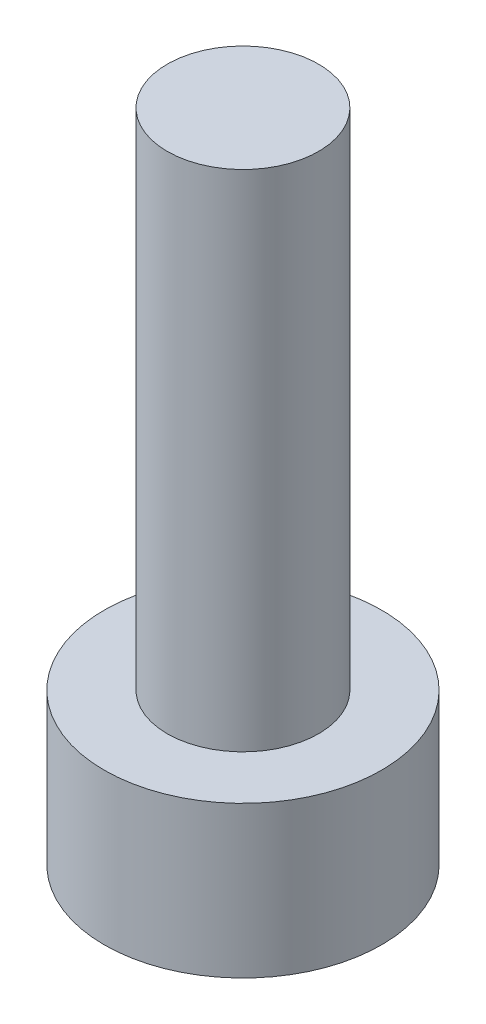
from build123d import *

# Parameters (mm, degrees)
SKETCH1_R           = 2.75
BOSS_EXTRUDE1_DEPTH = 3
SKETCH2_R           = 1.5
BOSS_EXTRUDE2_DEPTH = 10
CUT_EXTRUDE1_DEPTH  = 1.5


with BuildPart() as part:
    # Sketch1 → Boss-Extrude1 (new body)
    with BuildSketch(Plane(origin=(0, 0, 0), x_dir=(1, 0, 0), z_dir=(0, 1, 0))):
        Circle(SKETCH1_R)
    extrude(amount=BOSS_EXTRUDE1_DEPTH)

    # Sketch2 → Boss-Extrude2 (add)
    with BuildSketch(Plane(origin=(0, 3, 0), x_dir=(1, 0, 0), z_dir=(0, 1, 0))):
        Circle(SKETCH2_R)
    extrude(amount=BOSS_EXTRUDE2_DEPTH)

    # Sketch3 → Cut-Extrude1 (cut)
    with BuildSketch(Plane(origin=(0, 0, 0), x_dir=(-1, 0, 0), z_dir=(0, -1, 0))):
        Polygon((0, -1.443375673), (1.25, -0.721687836), (1.25, 0.721687836), (0, 1.443375673), (-1.25, 0.721687836), (-1.25, -0.721687836), align=None)
    extrude(amount=-CUT_EXTRUDE1_DEPTH, mode=Mode.SUBTRACT)


solid = part.part
